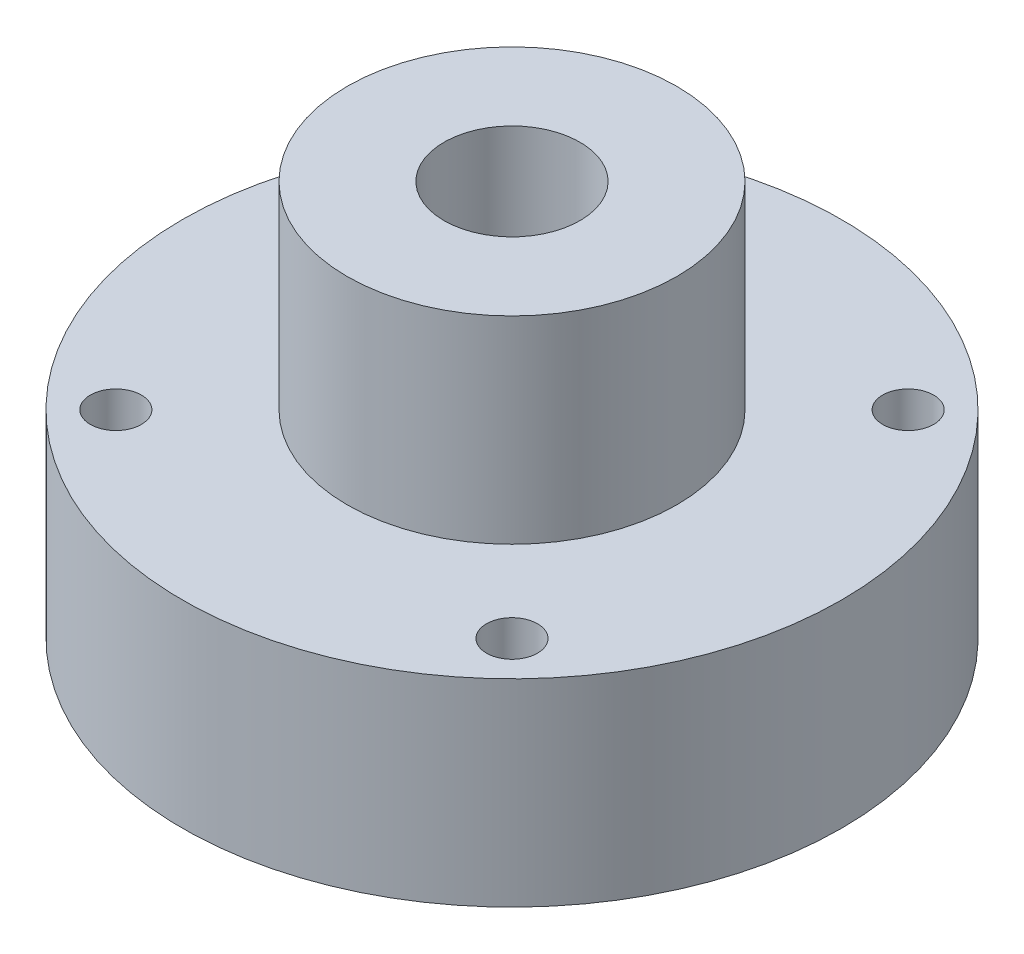
from build123d import *

# Parameters (mm, degrees)
F_10_0_1935_DIAMETER_HOLE1_D     = 4.9149
F_33_64_0_51563_DIAMETER_HOLE1_D = 13.097002


with BuildPart() as part:
    # Sketch1 → Revolve1 (revolve)
    with BuildSketch(Plane.XY):
        Polygon((-3.175, -19.05), (-12.7, -19.05), (-12.7, -38.1), align=None)
        Polygon((-12.7, -38.1), (-12.7, -19.05), (-3.175, -19.05), (-3.175, 0), (-15.875, 0), (-15.875, -19.05), (-31.75, -19.05), (-31.75, -38.1), (-23.8125, -38.1), (-23.8125, -34.9631), (-19.0373, -34.9631), (-19.0373, -38.1), align=None)
    revolve(axis=Axis((0, 0, 0), (0, -1, 0)))

    # #10 (0.1935) Diameter Hole1 (through all)
    with Locations(Plane(origin=(0, 0, 0), x_dir=(1, 0, 0), z_dir=(0, 1, 0))):
        with Locations((19.083044257, 19.083044257), (-19.083044257, 19.083044257), (-19.083044257, -19.083044257), (19.083044257, -19.083044257)):
            Hole(F_10_0_1935_DIAMETER_HOLE1_D / 2)

    # 33/64 (0.51563) Diameter Hole1 (through all)
    with Locations(Plane(origin=(0, 0, 0), x_dir=(1, 0, 0), z_dir=(0, 1, 0))):
        with Locations((0, 0)):
            Hole(F_33_64_0_51563_DIAMETER_HOLE1_D / 2)


solid = part.part
